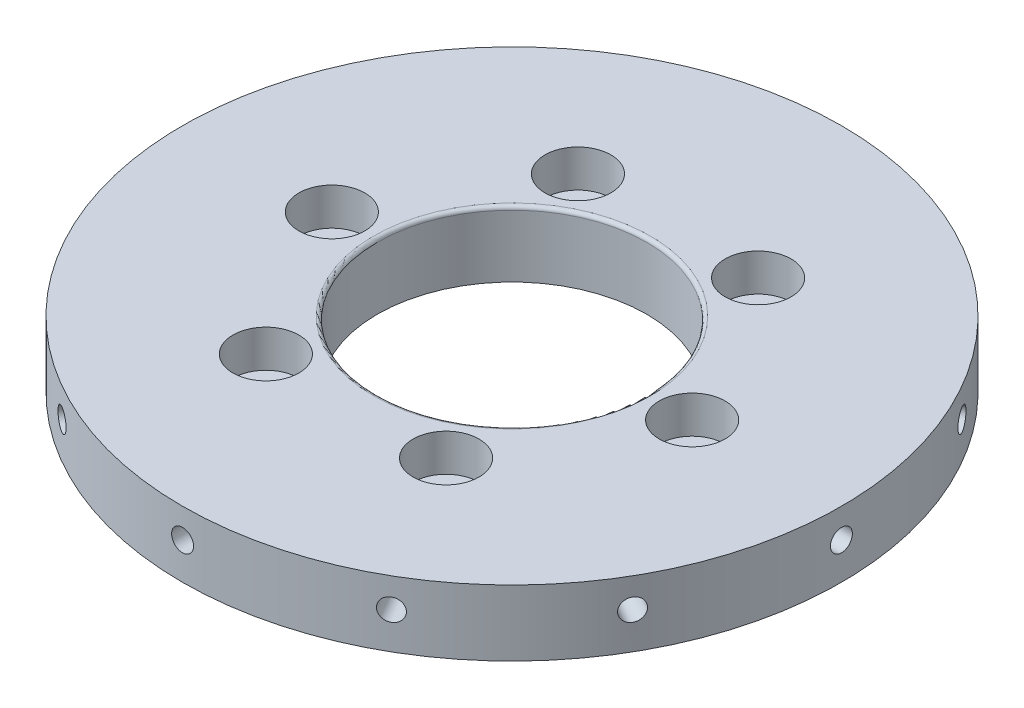
from build123d import *

# Parameters (mm, degrees)
SKETCH_1_R               = 45
SKETCH_1_R_2             = 2.5
SKETCH_1_R_3             = 18.4
EXTRUDE_1_DEPTH          = 9
SKETCH_2_R               = 4
CUT_EXTRUDE_1_DEPTH      = 3
SKETCH_4_R               = 4.5
CUT_EXTRUDE_2_DEPTH      = 5.1
SKETCH_5_R               = 1.5
CUT_EXTRUDE_3_DEPTH      = 10
PATTERN_CIRCULAR_1_COUNT = 12
FILLET_1_R               = 0.5


with BuildPart() as part:
    # 草图1 → 凸台-拉伸1 (new body)
    with BuildSketch(Plane(origin=(0, 0, 0), x_dir=(1, 0, 0), z_dir=(0, 1, 0))):
        Circle(SKETCH_1_R)
        with Locations((-24.6, 0)):
            Circle(SKETCH_1_R_2, mode=Mode.SUBTRACT)
        with Locations((-12.3, 21.304224933)):
            Circle(SKETCH_1_R_2, mode=Mode.SUBTRACT)
        with Locations((12.3, 21.304224933)):
            Circle(SKETCH_1_R_2, mode=Mode.SUBTRACT)
        with Locations((24.6, 0)):
            Circle(SKETCH_1_R_2, mode=Mode.SUBTRACT)
        with Locations((12.3, -21.304224933)):
            Circle(SKETCH_1_R_2, mode=Mode.SUBTRACT)
        with Locations((-12.3, -21.304224933)):
            Circle(SKETCH_1_R_2, mode=Mode.SUBTRACT)
        Circle(SKETCH_1_R_3, mode=Mode.SUBTRACT)
    extrude(amount=EXTRUDE_1_DEPTH)

    # 草图2 → 切除-拉伸1 (cut)
    with BuildSketch(Plane.XZ):
        with Locations((-21.304224933, -12.3)):
            Circle(SKETCH_2_R)
        with Locations((0, 24.6)):
            Circle(SKETCH_2_R)
        with Locations((21.304224933, -12.3)):
            Circle(SKETCH_2_R)
    extrude(amount=-CUT_EXTRUDE_1_DEPTH, mode=Mode.SUBTRACT)

    # 草图4 → 切除-拉伸2 (cut)
    with BuildSketch(Plane(origin=(0, 9, 0), x_dir=(1, 0, 0), z_dir=(0, 1, 0))):
        with Locations((-24.6, 0)):
            Circle(SKETCH_4_R)
        with Locations((-12.3, 21.304224933)):
            Circle(SKETCH_4_R)
        with Locations((12.3, 21.304224933)):
            Circle(SKETCH_4_R)
        with Locations((24.6, 0)):
            Circle(SKETCH_4_R)
        with Locations((12.3, -21.304224933)):
            Circle(SKETCH_4_R)
        with Locations((-12.3, -21.304224933)):
            Circle(SKETCH_4_R)
    extrude(amount=-CUT_EXTRUDE_2_DEPTH, mode=Mode.SUBTRACT)

    # 草图5 → 切除-拉伸3 (cut)
    with BuildSketch(Plane(origin=(45, 0, 0), x_dir=(0, 0, -1), z_dir=(1, 0, 0))):
        with Locations((0, 5)):
            Circle(SKETCH_5_R)
    cut_extrude_3 = extrude(amount=-CUT_EXTRUDE_3_DEPTH, mode=Mode.SUBTRACT)

    # 阵列(圆周)1: 切除-拉伸3 ×12 about axis
    pattern_circular_1_axis = Axis((0, 0, 0), (0, 1, 0))
    for i in range(1, PATTERN_CIRCULAR_1_COUNT):
        add(cut_extrude_3.rotate(pattern_circular_1_axis, i * 360 / PATTERN_CIRCULAR_1_COUNT), mode=Mode.SUBTRACT)

    # 圆角1
    fillet_1_edges = [part.edges().sort_by_distance(p)[0] for p in [
        (-18.4, 9, 0),
    ]]
    fillet(fillet_1_edges, radius=FILLET_1_R)


solid = part.part
